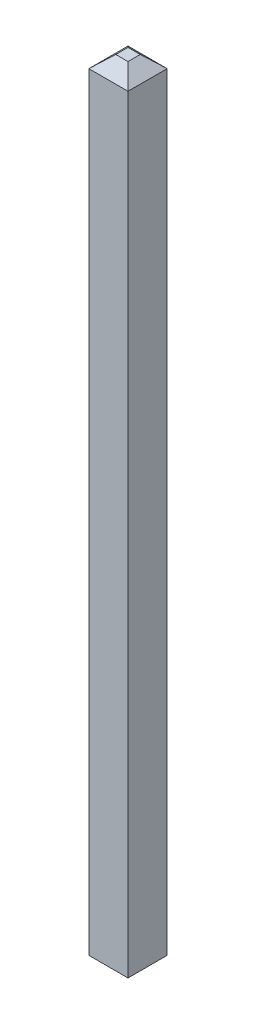
from build123d import *

# Parameters (mm, degrees)
SKETCH1_W           = 0.64
SKETCH1_H           = 0.64
BOSS_EXTRUDE1_DEPTH = 12.54
SKETCH3_W           = 0.2
SKETCH3_H           = 0.2
SKETCH4_W           = 0.2
SKETCH4_H           = 0.2


with BuildPart() as part:
    # Sketch1 → Boss-Extrude1 (new body)
    with BuildSketch(Plane(origin=(0, 0, 0), x_dir=(1, 0, 0), z_dir=(0, 1, 0))):
        Rectangle(SKETCH1_W, SKETCH1_H)
    extrude(amount=BOSS_EXTRUDE1_DEPTH)

    # Sketch3 → section 0 of loft1
    with BuildSketch(Plane(origin=(0, 12.74, 0), x_dir=(1, 0, 0), z_dir=(0, 1, 0)), mode=Mode.PRIVATE) as loft1_s0:
        Rectangle(SKETCH3_W, SKETCH3_H)
    # loft up to a face of the part (loft1)
    loft([loft1_s0.sketch, part.faces().sort_by_distance((0, 12.54, 0))[0]])

    # Sketch4 → section 0 of loft2
    with BuildSketch(Plane(origin=(0, -0.2, 0), x_dir=(-1, 0, 0), z_dir=(0, -1, 0)), mode=Mode.PRIVATE) as loft2_s0:
        Rectangle(SKETCH4_W, SKETCH4_H)
    # loft up to a face of the part (loft2)
    loft([loft2_s0.sketch, part.faces().sort_by_distance((0, 0, 0))[0]])


solid = part.part
